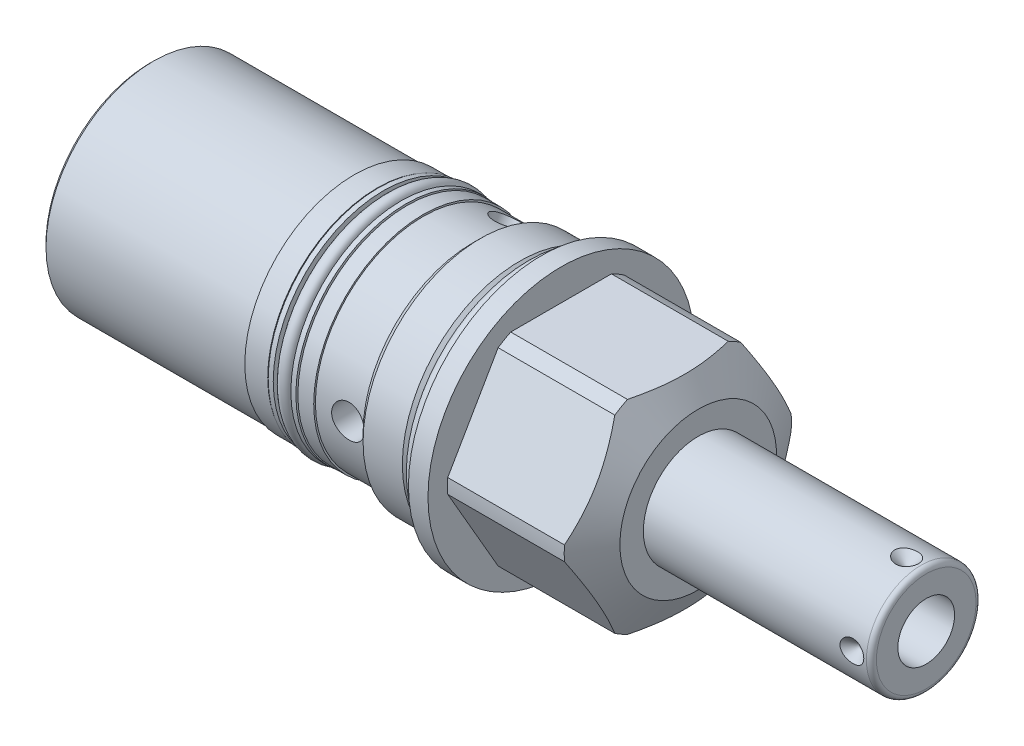
from build123d import *

# Parameters (mm, degrees)
SKETCH1_R           = 26.9875
EXTRUDE1_DEPTH      = 31.75
EXTRUDE1_DEPTH_BACK = 79.375
CUT_EXTRUDE1_REACH  = 81.375
SKETCH2_R           = 26.9875
SKETCH2_R_2         = 23.8125
CUT_EXTRUDE3_REACH  = 31.362
CUT_EXTRUDE3_START  = -0.7874
SKETCH5_R           = 26.9875
CUT_EXTRUDE5_REACH  = 29.788
SKETCH7_R           = 26.9875
SKETCH7_R_2         = 23.0251
SKETCH12_W          = 6.1087
SKETCH12_H          = 2.032
SKETCH14_W          = 0.3429
SKETCH14_H          = 41.402
SKETCH14_H_2        = 10.0076
SKETCH15_R          = 1.4986
SKETCH16_W          = 2.1844
SKETCH16_H          = 1.016
SKETCH17_R          = 1.3081
CIRPATTERN1_COUNT   = 4
CHAMFER1_SIZE       = 0.762
SKETCH23_R          = 3.3147
CUT_EXTRUDE7_DEPTH  = 27.9875
SKETCH26_R          = 17.7927
EXTRUDE2_DEPTH      = 0.508
SKETCH27_R          = 6.1849
CUT_EXTRUDE8_DEPTH  = 0.508
CIRPATTERN2_COUNT   = 3


with BuildPart() as part:
    # Sketch1 → Extrude1 (new body, two sides)
    with BuildSketch(Plane(origin=(0, 0, 0), x_dir=(0, 0, -1), z_dir=(1, 0, 0))) as extrude1_sk:
        Circle(SKETCH1_R)
    extrude(amount=EXTRUDE1_DEPTH)
    extrude(extrude1_sk.sketch, amount=-EXTRUDE1_DEPTH_BACK)

    # Sketch2 → Cut-Extrude1 (cut, up to next)
    with BuildSketch(Plane(origin=(0, 0, 0), x_dir=(0, 0, -1), z_dir=(1, 0, 0)), mode=Mode.PRIVATE) as cut_extrude1_sk1:
        Circle(SKETCH2_R)
        Circle(SKETCH2_R_2, mode=Mode.SUBTRACT)
    cut_extrude1_tool1 = extrude(cut_extrude1_sk1.sketch, amount=-CUT_EXTRUDE1_REACH, mode=Mode.PRIVATE) & part.part
    add(cut_extrude1_tool1.solids().sort_by_distance((0, 0, 26.224178))[0], mode=Mode.SUBTRACT)

    # Sketch3 → Cut-Revolve1 (revolve, cut)
    with BuildSketch(Plane.XY, mode=Mode.PRIVATE) as cut_revolve1_sk:
        Polygon((25.334195134, 26.9875), (31.75, 15.875), (31.75, 26.9875), align=None)
    revolve(cut_revolve1_sk.sketch.rotate(Axis((-8.14577342, 0, 0), (1, 0, 0)), 270), axis=Axis((-8.14577342, 0, 0), (1, 0, 0)), mode=Mode.SUBTRACT)  # turned: the seam where the file's is

    # Cut-Extrude3: up to this cone (the profile starts inside it)
    cut_extrude3_end = Plane(origin=(3.9624, 0, 0), z_dir=(-1, 0, 0)).offset(-36.953034523) * Cone(1.732e-06, 230.050244421, 132.819569544, align=(Align.CENTER, Align.CENTER, Align.MIN), mode=Mode.PRIVATE)
    # Sketch5 → Cut-Extrude3 (cut, up to the surface)
    with BuildSketch(Plane.ZY.offset(-3.175).offset(CUT_EXTRUDE3_START), mode=Mode.PRIVATE) as cut_extrude3_sk1:
        with Locations(Location((0, 0, 0), (0, 0, 180))):  # turned: the seam where the file's is
            Circle(SKETCH5_R)
        Polygon((-11.91506618, 20.6375), (11.91506618, 20.6375), (23.830132361, 0), (11.91506618, -20.6375), (-11.91506618, -20.6375), (-23.830132361, 0), align=None, mode=Mode.SUBTRACT)
    cut_extrude3_tool1 = extrude(cut_extrude3_sk1.sketch, amount=-CUT_EXTRUDE3_REACH, mode=Mode.PRIVATE) & cut_extrude3_end
    add(cut_extrude3_tool1.solids().sort_by_distance((3.9624, 0, 26.224178))[0], mode=Mode.SUBTRACT)

    # Cut-Extrude5: up to this cone (the profile starts inside it)
    cut_extrude5_end = Plane(origin=(3.9624, 0, 0), z_dir=(-1, 0, 0)).offset(-36.953034523) * Cone(1.732e-06, 227.32399645, 131.245569544, align=(Align.CENTER, Align.CENTER, Align.MIN), mode=Mode.PRIVATE)
    # Sketch7 → Cut-Extrude5 (cut, up to the surface)
    with BuildSketch(Plane.ZY.offset(-3.9624), mode=Mode.PRIVATE) as cut_extrude5_sk1:
        with Locations(Location((0, 0, 0), (0, 0, 180))):  # turned: the seam where the file's is
            Circle(SKETCH7_R)
        Circle(SKETCH7_R_2, mode=Mode.SUBTRACT)
    cut_extrude5_tool1 = extrude(cut_extrude5_sk1.sketch, amount=-CUT_EXTRUDE5_REACH, mode=Mode.PRIVATE) & cut_extrude5_end
    add(cut_extrude5_tool1.solids().sort_by_distance((3.9624, 0, 26.224178))[0], mode=Mode.SUBTRACT)

    # Sketch9 → Cut-Revolve3 (revolve, cut)
    with BuildSketch(Plane.XY, mode=Mode.PRIVATE) as cut_revolve3_sk:
        Polygon((0, 23.8125), (0, 22.3012), (-2.8956, 22.3012), (-4.4069, 23.8125), align=None)
    revolve(cut_revolve3_sk.sketch.rotate(Axis((-4.4205525, 0, 0), (1, 0, 0)), 90), axis=Axis((-4.4205525, 0, 0), (1, 0, 0)), mode=Mode.SUBTRACT)  # turned: the seam where the file's is

    # Sketch10 → Cut-Revolve4 (revolve, cut)
    with BuildSketch(Plane.XY, mode=Mode.PRIVATE) as cut_revolve4_sk:
        Polygon((-12.3698, 23.8125), (-13.9954, 22.1869), (-79.375, 22.1869), (-79.375, 23.8125), align=None)
    revolve(cut_revolve4_sk.sketch.rotate(Axis((-55.9469925, 0, 0), (1, 0, 0)), 90), axis=Axis((-55.9469925, 0, 0), (1, 0, 0)), mode=Mode.SUBTRACT)  # turned: the seam where the file's is

    # Sketch12 → Cut-Revolve6 (revolve, cut)
    with BuildSketch(Plane.XY, mode=Mode.PRIVATE) as cut_revolve6_sk:
        with Locations((-30.27045, 21.1709)):
            Rectangle(SKETCH12_W, SKETCH12_H)
    revolve(cut_revolve6_sk.sketch.rotate(Axis((-31.750635, 0, 0), (1, 0, 0)), 90), axis=Axis((-31.750635, 0, 0), (1, 0, 0)), mode=Mode.SUBTRACT)  # turned: the seam where the file's is

    # Sketch14 → Cut-Revolve8 (revolve, cut)
    with BuildSketch(Plane(origin=(0, 0, 0), x_dir=(0, -1, 0), z_dir=(0, 0, 1)), mode=Mode.PRIVATE) as cut_revolve8_sk:
        with Locations((22.01545, -58.674)):
            Rectangle(SKETCH14_W, SKETCH14_H)
        with Locations((22.01545, -18.9992)):
            Rectangle(SKETCH14_W, SKETCH14_H_2)
    revolve(cut_revolve8_sk.sketch.rotate(Axis((-55.86603, 0, 0), (1, 0, 0)), 270), axis=Axis((-55.86603, 0, 0), (1, 0, 0)), mode=Mode.SUBTRACT)  # turned: the seam where the file's is

    # Sketch16 → Revolve2 (revolve)
    with BuildSketch(Plane(origin=(0, 0, 0), x_dir=(0, -1, 0), z_dir=(0, 0, 1)), mode=Mode.PRIVATE) as revolve2_sk:
        with Locations((21.2471, -27.9781)):
            Rectangle(SKETCH16_W, SKETCH16_H)
        with Locations((21.2471, -32.5628)):
            Rectangle(SKETCH16_W, SKETCH16_H)
    revolve(revolve2_sk.sketch.rotate(Axis((-31.471235, 0, 0), (1, 0, 0)), 270), axis=Axis((-31.471235, 0, 0), (1, 0, 0)))  # turned: the seam where the file's is

    # S2D0001 → Revolve4 (revolve)
    with BuildSketch(Plane(origin=(0, 0, 0), x_dir=(0, -1, 0), z_dir=(0, 0, 1)), mode=Mode.PRIVATE) as revolve4_sk:
        with BuildLine():
            Line((0, 31.75), (-11.1125, 31.75))
            Line((-11.1125, 31.75), (-11.1125, 76.962))
            ThreePointArc((-11.1125, 76.962), (-10.81492049, 77.68042049), (-10.0965, 77.978))
            Line((-10.0965, 77.978), (0, 77.978))
            Line((0, 77.978), (0, 31.75))
        make_face()
    revolve(revolve4_sk.sketch.rotate(Axis((7.265766347, 0, 0), (1, 0, 0)), 90), axis=Axis((7.265766347, 0, 0), (1, 0, 0)))  # turned: the seam where the file's is

    # Sketch19 → Cut-Revolve9 (revolve, cut)
    with BuildSketch(Plane(origin=(36.322, -2.8067, 0), x_dir=(0, -1, 0), z_dir=(0, 0, 1)), mode=Mode.PRIVATE) as cut_revolve9_sk:
        Polygon((2.9464, 41.656), (2.9464, 24.638), (-2.8067, 21.181188773), (-2.8067, 41.656), align=None)
    revolve(cut_revolve9_sk.sketch.rotate(Axis((17.699325537, 0, 0), (1, 0, 0)), 270), axis=Axis((17.699325537, 0, 0), (1, 0, 0)), mode=Mode.SUBTRACT)  # turned: the seam where the file's is

    # S2D0002 → Cut-Revolve10 (revolve, cut)
    with BuildSketch(Plane(origin=(32.3596, 0, -5.55625), x_dir=(1, 0, 0), z_dir=(0, 1, 0)), mode=Mode.PRIVATE) as cut_revolve10_sk:
        Polygon((41.656, 5.55625), (44.069, 5.55625), (41.656, 3.14325), align=None)
    cut_revolve10 = revolve(cut_revolve10_sk.sketch.rotate(Axis((74.0156, 0, -2.191027232), (0, 0, -1)), 180), axis=Axis((74.0156, 0, -2.191027232), (0, 0, -1)), mode=Mode.SUBTRACT)  # turned: the seam where the file's is

    # CirPattern1: Cut-Revolve10 ×4 about axis
    cirpattern1_axis = Axis((7.265766347, 0, 0), (-1, 0, 0))
    for i in range(1, CIRPATTERN1_COUNT):
        add(cut_revolve10.rotate(cirpattern1_axis, i * 360 / CIRPATTERN1_COUNT), mode=Mode.SUBTRACT)

    # Chamfer1
    chamfer1_edges = [part.edges().sort_by_distance(p)[0] for p in [
        (-79.375, 0, -21.844),
    ]]
    chamfer(chamfer1_edges, length=CHAMFER1_SIZE)

    # Sketch23 → Cut-Extrude7 (cut, through all)
    with BuildSketch(Plane.XY):
        with Locations((-17.399, 0)):
            Circle(SKETCH23_R)
    cut_extrude7 = extrude(amount=CUT_EXTRUDE7_DEPTH, mode=Mode.SUBTRACT)

    # Sketch24 → Cut-Revolve11 (revolve, cut)
    with BuildSketch(Plane.XY, mode=Mode.PRIVATE) as cut_revolve11_sk:
        Polygon((-79.375, 6.1849), (-76.8223, 5.642306865), (-76.158393135, 4.9784), (-65.1002, 4.9784), (-65.1002, 0), (-79.375, 0), align=None)
    revolve(cut_revolve11_sk.sketch.rotate(Axis((0, 0, 0), (-1, 0, 0)), 270), axis=Axis((0, 0, 0), (-1, 0, 0)), mode=Mode.SUBTRACT)  # turned: the seam where the file's is

    # Sketch26 → Extrude2 (add)
    with BuildSketch(Plane.ZY.offset(79.375)):
        with Locations(Location((0, 0, 0), (0, 0, 180))):  # turned: the seam where the file's is
            Circle(SKETCH26_R)
    extrude(amount=EXTRUDE2_DEPTH)

    # Sketch27 → Cut-Extrude8 (cut)
    with BuildSketch(Plane.ZY.offset(79.883)):
        Circle(SKETCH27_R)
    extrude(amount=-CUT_EXTRUDE8_DEPTH, mode=Mode.SUBTRACT)

    # CirPattern2: Cut-Extrude7 ×3 about axis
    cirpattern2_axis = Axis((7.265766347, 0, 0), (-1, 0, 0))
    for i in range(1, CIRPATTERN2_COUNT):
        add(cut_extrude7.rotate(cirpattern2_axis, i * 360 / CIRPATTERN2_COUNT), mode=Mode.SUBTRACT)


with BuildPart() as body_2:
    # Sketch15 → Revolve1 (revolve)
    with BuildSketch(Plane(origin=(0, 0, 0), x_dir=(0, -1, 0), z_dir=(0, 0, 1)), mode=Mode.PRIVATE) as revolve1_sk:
        with Locations((23.7998, -1.4986)):
            Circle(SKETCH15_R)
    revolve(revolve1_sk.sketch.rotate(Axis((-3.09372, 0, 0), (1, 0, 0)), 270), axis=Axis((-3.09372, 0, 0), (1, 0, 0)))  # turned: the seam where the file's is


with BuildPart() as body_3:
    # Sketch17 → Revolve3 (revolve)
    with BuildSketch(Plane(origin=(0, 0, 0), x_dir=(0, -1, 0), z_dir=(0, 0, 1)), mode=Mode.PRIVATE) as revolve3_sk:
        with Locations((21.463, -30.27045)):
            Circle(SKETCH17_R)
    revolve(revolve3_sk.sketch.rotate(Axis((-31.750635, 0, 0), (1, 0, 0)), 270), axis=Axis((-31.750635, 0, 0), (1, 0, 0)))  # turned: the seam where the file's is


solid = Compound([part.part, body_2.part, body_3.part])
